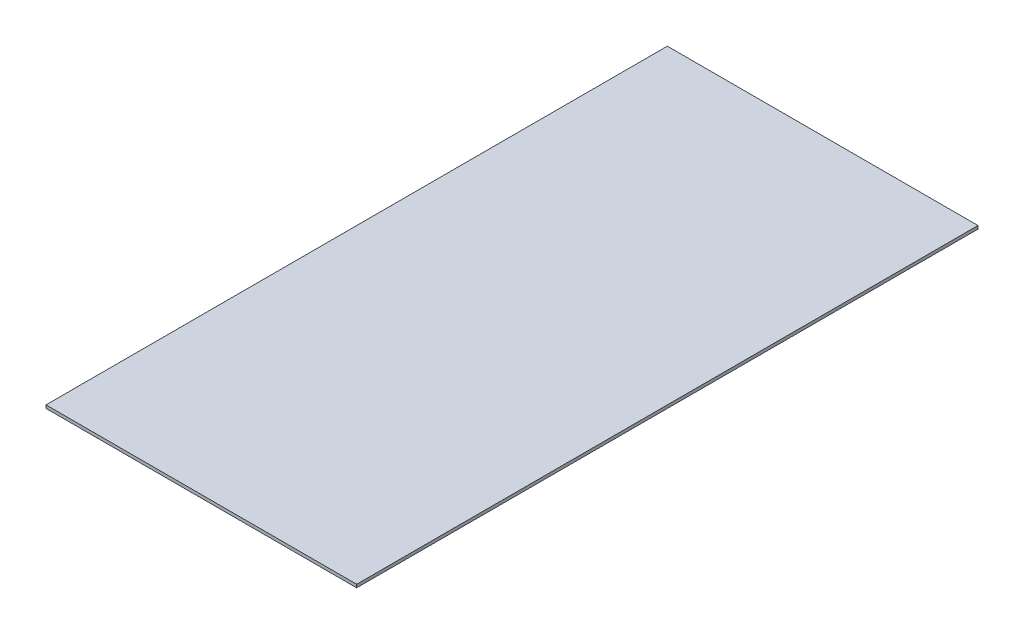
from build123d import *

# Parameters (mm, degrees)
SKETCH1_W           = 1000
SKETCH1_H           = 2000
BOSS_EXTRUDE1_DEPTH = 5


with BuildPart() as part:
    # Sketch1 → Boss-Extrude1 (new body, symmetric)
    with BuildSketch(Plane(origin=(0, 0, 0), x_dir=(1, 0, 0), z_dir=(0, 1, 0))):
        Rectangle(SKETCH1_W, SKETCH1_H)
    extrude(amount=BOSS_EXTRUDE1_DEPTH, both=True)


solid = part.part
